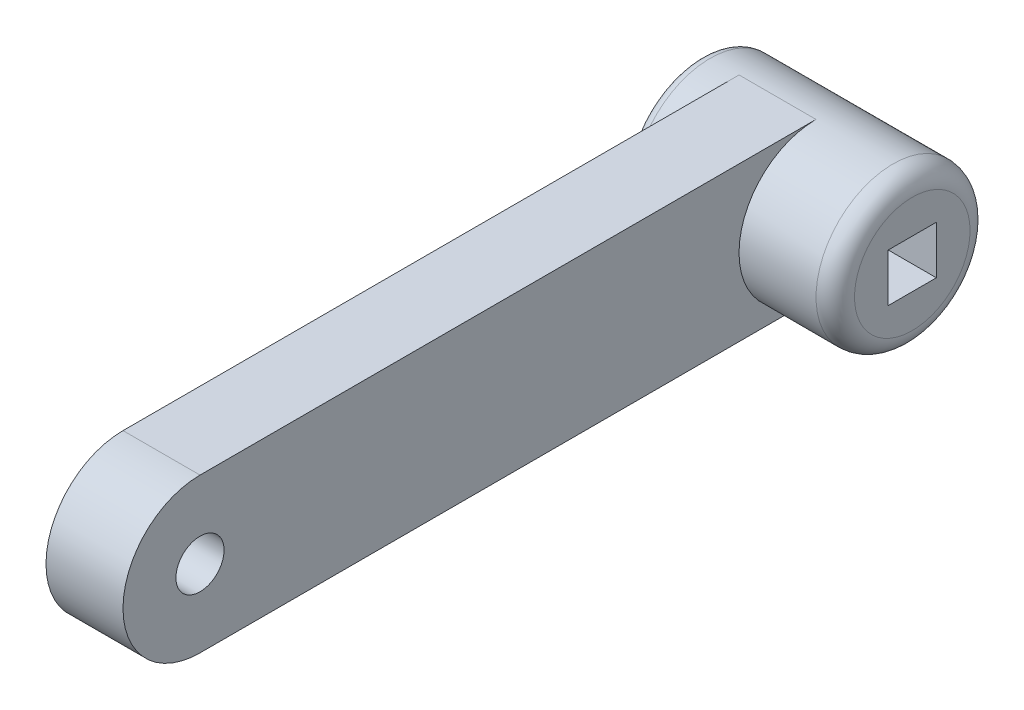
from build123d import *

# Parameters (mm, degrees)
SKETCH1_R           = 10.16
BOSS_EXTRUDE1_DEPTH = 10.16
FILLET1_R           = 1.27
BOSS_EXTRUDE2_DEPTH = 5.08
SKETCH3_R           = 10.16
BOSS_EXTRUDE3_DEPTH = 7.62
FILLET2_R           = 2.54
SKETCH4_W           = 6.35
SKETCH4_H           = 6.35
CUT_EXTRUDE1_DEPTH  = 25.4
SKETCH5_R           = 3.175
CUT_EXTRUDE2_DEPTH  = 16.24


with BuildPart() as part:
    # Sketch1 → Boss-Extrude1 (new body, symmetric)
    with BuildSketch(Plane(origin=(0, 0, 0), x_dir=(0, 0, -1), z_dir=(1, 0, 0))):
        Circle(SKETCH1_R)
    extrude(amount=BOSS_EXTRUDE1_DEPTH, both=True)

    # Fillet1
    fillet1_edges = [part.edges().sort_by_distance(p)[0] for p in [
        (-10.16, 0, 10.16),
    ]]
    fillet(fillet1_edges, radius=FILLET1_R)

    # Sketch2 → Boss-Extrude2 (add, symmetric)
    with BuildSketch(Plane(origin=(0, 0, 0), x_dir=(0, 0, -1), z_dir=(1, 0, 0))):
        with BuildLine():
            Line((-81.28, 10.16), (0, 10.16))
            ThreePointArc((0, 10.16), (10.16, 0), (0, -10.16))
            Line((0, -10.16), (-81.28, -10.16))
            ThreePointArc((-81.28, -10.16), (-91.44, 0), (-81.28, 10.16))
        make_face()
    extrude(amount=BOSS_EXTRUDE2_DEPTH, both=True)

    # Sketch3 → Boss-Extrude3 (add)
    with BuildSketch(Plane(origin=(10.16, 0, 0), x_dir=(0, 0, -1), z_dir=(1, 0, 0))):
        Circle(SKETCH3_R)
    extrude(amount=BOSS_EXTRUDE3_DEPTH)

    # Fillet2
    fillet2_edges = [part.edges().sort_by_distance(p)[0] for p in [
        (17.78, 0, 10.16),
    ]]
    fillet(fillet2_edges, radius=FILLET2_R)

    # Sketch4 → Cut-Extrude1 (cut)
    with BuildSketch(Plane(origin=(17.78, 0, 0), x_dir=(0, 0, -1), z_dir=(1, 0, 0))):
        Rectangle(SKETCH4_W, SKETCH4_H)
    extrude(amount=-CUT_EXTRUDE1_DEPTH, mode=Mode.SUBTRACT)

    # Sketch5 → Cut-Extrude2 (cut, through all)
    with BuildSketch(Plane(origin=(5.08, 0, 0), x_dir=(0, 0, -1), z_dir=(1, 0, 0))):
        with Locations((-81.28, 0)):
            Circle(SKETCH5_R)
    extrude(amount=-CUT_EXTRUDE2_DEPTH, mode=Mode.SUBTRACT)


solid = part.part
